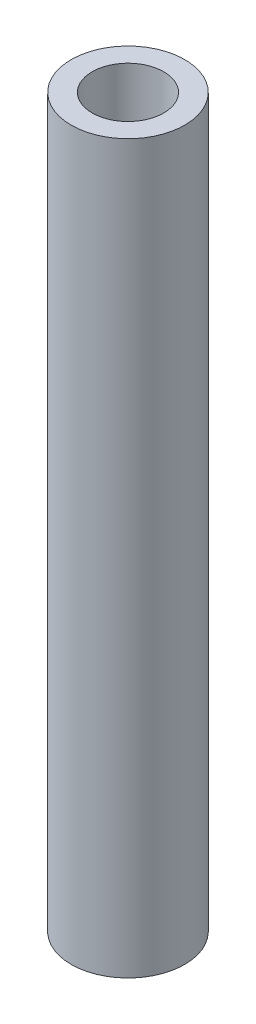
from build123d import *

# Parameters (mm, degrees)
SKETCH1_R           = 3.175
SKETCH1_R_2         = 2
BOSS_EXTRUDE1_DEPTH = 40.64


with BuildPart() as part:
    # Sketch1 → Boss-Extrude1 (new body)
    with BuildSketch(Plane(origin=(0, 0, 0), x_dir=(1, 0, 0), z_dir=(0, 1, 0))):
        Circle(SKETCH1_R)
        Circle(SKETCH1_R_2, mode=Mode.SUBTRACT)
    extrude(amount=-BOSS_EXTRUDE1_DEPTH)


solid = part.part
